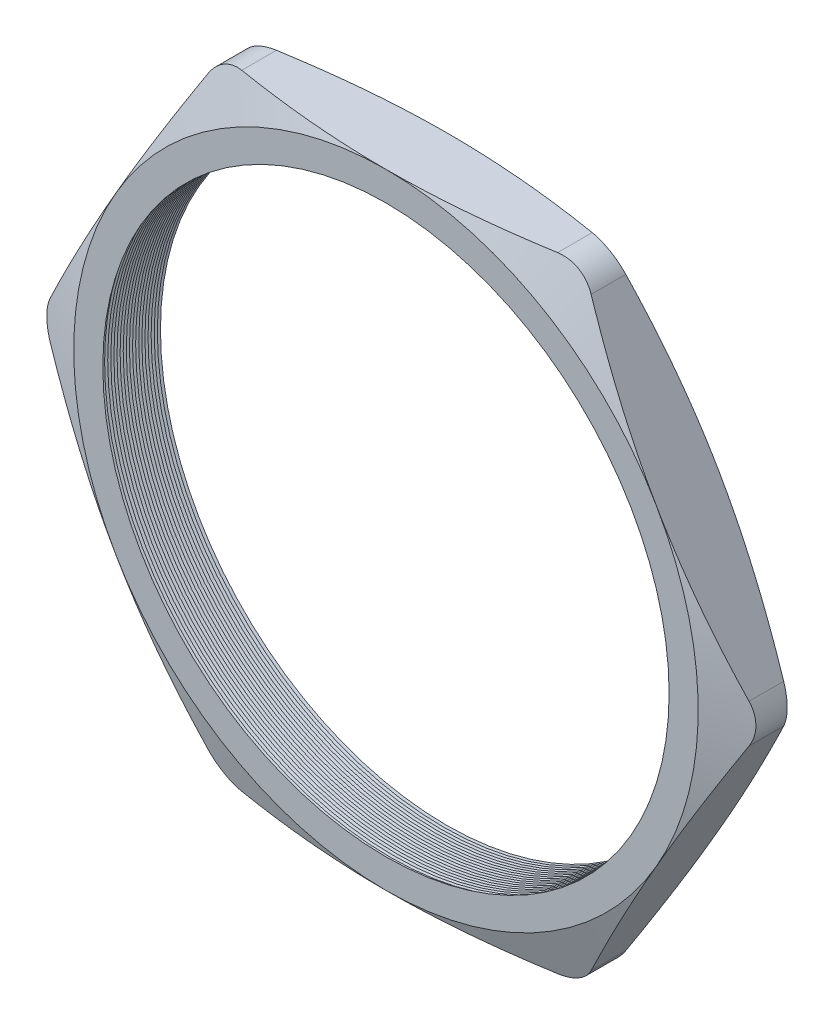
from build123d import *

# Parameters (mm, degrees)
SKETCH1_R          = 18.542
EXTRUDE1_DEPTH     = 4.064
FILLET1_R          = 2.54
SKETCH2_OUTSIDE_W  = 88.662
SKETCH2_OUTSIDE_H  = 83.122
SKETCH2_OUTSIDE_R  = 20.447
CUT_EXTRUDE1_DEPTH = 5.064
CUT_EXTRUDE1_DRAFT = -70
SKETCH3_OUTSIDE_W  = 88.662
SKETCH3_OUTSIDE_H  = 83.122
SKETCH3_OUTSIDE_R  = 20.447
CUT_EXTRUDE2_DEPTH = 5.0640001
CUT_EXTRUDE2_DRAFT = -70
LPATTERN1_COUNT    = 20
LPATTERN1_PITCH    = 0.2032


with BuildPart() as part:
    # Sketch1 → Extrude1 (new body)
    with BuildSketch(Plane.XY):
        Polygon((-23.610161908, 0), (-11.805080954, -20.447), (11.805080954, -20.447), (23.610161908, 0), (11.805080954, 20.447), (-11.805080954, 20.447), align=None)
        Circle(SKETCH1_R, mode=Mode.SUBTRACT)
    extrude(amount=EXTRUDE1_DEPTH)

    # Fillet1
    fillet1_edges = [part.edges().sort_by_distance(p)[0] for p in [
        (23.610161908, 0, 2.032),
        (11.805080954, -20.447, 2.032),
        (-11.805080954, -20.447, 2.032),
        (-23.610161908, 0, 2.032),
        (-11.805080954, 20.447, 2.032),
        (11.805080954, 20.447, 2.032),
    ]]
    fillet(fillet1_edges, radius=FILLET1_R)


with BuildPart() as cut_extrude1_tool:
    # Sketch2 outside → Cut-Extrude1 (with draft: the straight prism first)
    with BuildSketch(Plane.XY.offset(4.064)):
        Rectangle(SKETCH2_OUTSIDE_W, SKETCH2_OUTSIDE_H)
        Circle(SKETCH2_OUTSIDE_R, mode=Mode.SUBTRACT)
    extrude(amount=-CUT_EXTRUDE1_DEPTH)
    # Cut-Extrude1: the draft: its side faces are tilted about the plane it starts from
    cut_extrude1_sides = [cut_extrude1_tool.faces().sort_by_distance(p)[0] for p in [
        (0, -41.561, 1.532),
        (44.331, 0, 1.532),
        (0, 41.561, 1.532),
        (-44.331, 0, 1.532),
        (-20.447, 0, 1.532),
    ]]
    draft(cut_extrude1_sides, Plane.XY.offset(4.064), CUT_EXTRUDE1_DRAFT)


with BuildPart() as part_1:
    add(part.part)

    # Cut-Extrude1: cut by cut_extrude1_tool
    add(cut_extrude1_tool.part, mode=Mode.SUBTRACT)


with BuildPart() as cut_extrude2_tool:
    # Sketch3 outside → Cut-Extrude2 (with draft: the straight prism first)
    with BuildSketch(Plane(origin=(0, 0, 0), x_dir=(-1, 0, 0), z_dir=(0, 0, -1))):
        Rectangle(SKETCH3_OUTSIDE_W, SKETCH3_OUTSIDE_H)
        Circle(SKETCH3_OUTSIDE_R, mode=Mode.SUBTRACT)
    extrude(amount=-CUT_EXTRUDE2_DEPTH)
    # Cut-Extrude2: the draft: its side faces are tilted about the plane it starts from
    cut_extrude2_sides = [cut_extrude2_tool.faces().sort_by_distance(p)[0] for p in [
        (0, -41.561, 2.53200005),
        (-44.331, 0, 2.53200005),
        (0, 41.561, 2.53200005),
        (44.331, 0, 2.53200005),
        (20.447, 0, 2.53200005),
    ]]
    draft(cut_extrude2_sides, Plane(origin=(0, 0, 0), x_dir=(-1, 0, 0), z_dir=(0, 0, -1)), CUT_EXTRUDE2_DRAFT)


with BuildPart() as part_2:
    add(part_1.part)

    # Cut-Extrude2: cut by cut_extrude2_tool
    add(cut_extrude2_tool.part, mode=Mode.SUBTRACT)

    # Sketch4 → Cut-Revolve1 (revolve, cut)
    with BuildSketch(Plane(origin=(0, 0, 0), x_dir=(1, 0, 0), z_dir=(0, 1, 0))):
        Polygon((-18.542, -4.064), (-18.542, -3.624059095), (-18.923, -3.844029547), align=None)
    cut_revolve1 = revolve(axis=Axis((0, 0, 4.064), (0, 0, -1)), mode=Mode.SUBTRACT)

    # LPattern1: Cut-Revolve1 ×20
    with Locations(*[(0, 0, -i * LPATTERN1_PITCH) for i in range(1, LPATTERN1_COUNT)]):
        add(cut_revolve1, mode=Mode.SUBTRACT)


solid = part_2.part
